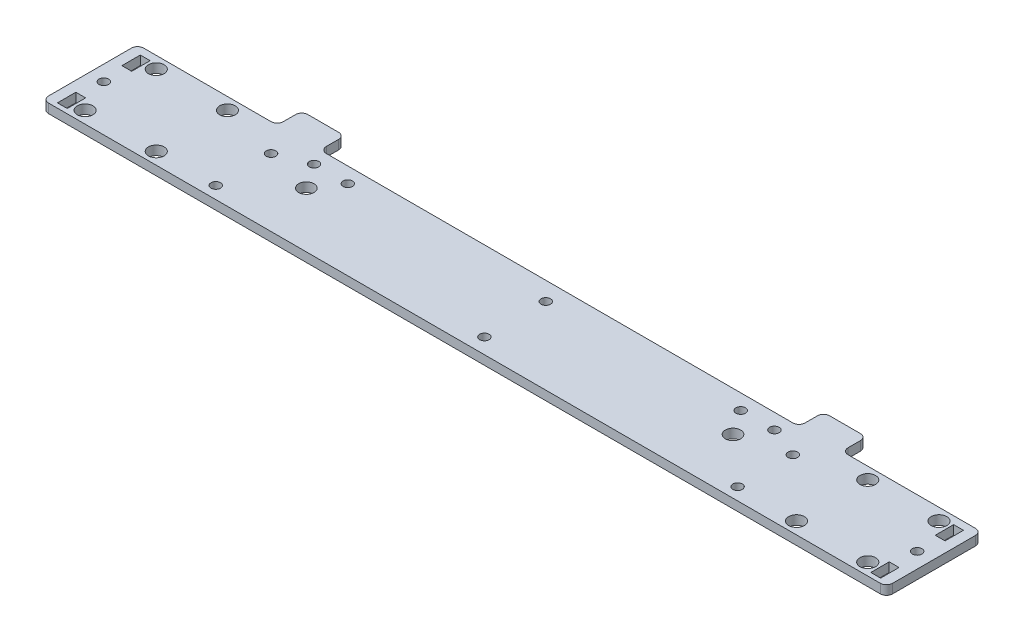
from build123d import *

# Parameters (mm, degrees)
CROQUIS1_R              = 1.55
CROQUIS1_R_2            = 2.55
CROQUIS1_R_3            = 2.5
CROQUIS1_W              = 3.2
CROQUIS1_H              = 6
SALIENTE_EXTRUIR1_DEPTH = 3
REDONDEO2_R             = 2


with BuildPart() as part:
    # Croquis1 → Saliente-Extruir1 (new body)
    with BuildSketch(Plane(origin=(0, 0, 0), x_dir=(1, 0, 0), z_dir=(0, 1, 0))):
        Polygon((0, 0), (275, 0), (275, 31), (229.5, 31), (229.5, 39), (215.5, 39), (215.5, 31), (59.5, 31), (59.5, 39), (45.5, 39), (45.5, 31), (0, 31), align=None)
        with Locations((5, 15)):
            Circle(CROQUIS1_R, mode=Mode.SUBTRACT)
        with Locations((270, 15)):
            Circle(CROQUIS1_R, mode=Mode.SUBTRACT)
        with Locations((10, 27.1)):
            Circle(CROQUIS1_R_2, mode=Mode.SUBTRACT)
        with Locations((33.2, 27.1)):
            Circle(CROQUIS1_R_2, mode=Mode.SUBTRACT)
        with Locations((33.2, 3.9)):
            Circle(CROQUIS1_R_2, mode=Mode.SUBTRACT)
        with Locations((10, 3.9)):
            Circle(CROQUIS1_R_2, mode=Mode.SUBTRACT)
        with Locations((265, 3.9)):
            Circle(CROQUIS1_R_2, mode=Mode.SUBTRACT)
        with Locations((241.8, 3.9)):
            Circle(CROQUIS1_R_2, mode=Mode.SUBTRACT)
        with Locations((265, 27.1)):
            Circle(CROQUIS1_R_2, mode=Mode.SUBTRACT)
        with Locations((241.8, 27.1)):
            Circle(CROQUIS1_R_2, mode=Mode.SUBTRACT)
        with Locations((139, 25)):
            Circle(CROQUIS1_R, mode=Mode.SUBTRACT)
        with Locations((139, 5)):
            Circle(CROQUIS1_R, mode=Mode.SUBTRACT)
        with Locations((52.5, 22)):
            Circle(CROQUIS1_R, mode=Mode.SUBTRACT)
        with Locations((52.5, 4)):
            Circle(CROQUIS1_R, mode=Mode.SUBTRACT)
        with Locations((222.5, 22)):
            Circle(CROQUIS1_R, mode=Mode.SUBTRACT)
        with Locations((222.5, 4)):
            Circle(CROQUIS1_R, mode=Mode.SUBTRACT)
        with Locations((212.5, 26)):
            Circle(CROQUIS1_R, mode=Mode.SUBTRACT)
        with Locations((62.5, 26)):
            Circle(CROQUIS1_R, mode=Mode.SUBTRACT)
        with Locations((201.5, 26)):
            Circle(CROQUIS1_R, mode=Mode.SUBTRACT)
        with Locations((73.5, 26)):
            Circle(CROQUIS1_R, mode=Mode.SUBTRACT)
        with Locations((207, 18)):
            Circle(CROQUIS1_R_3, mode=Mode.SUBTRACT)
        with Locations((68, 18)):
            Circle(CROQUIS1_R_3, mode=Mode.SUBTRACT)
        with Locations((270, 4.5)):
            Rectangle(CROQUIS1_W, CROQUIS1_H, mode=Mode.SUBTRACT)
        with Locations((5, 25.5)):
            Rectangle(CROQUIS1_W, CROQUIS1_H, mode=Mode.SUBTRACT)
        with Locations((5, 4.5)):
            Rectangle(CROQUIS1_W, CROQUIS1_H, mode=Mode.SUBTRACT)
        with Locations((270, 25.5)):
            Rectangle(CROQUIS1_W, CROQUIS1_H, mode=Mode.SUBTRACT)
    extrude(amount=SALIENTE_EXTRUIR1_DEPTH)

    # Redondeo2
    redondeo2_edges = [part.edges().sort_by_distance(p)[0] for p in [
        (0, 1.5, -31),
        (45.5, 1.5, -31),
        (45.5, 1.5, -39),
        (59.5, 1.5, -39),
        (59.5, 1.5, -31),
        (215.5, 1.5, -31),
        (215.5, 1.5, -39),
        (229.5, 1.5, -39),
        (229.5, 1.5, -31),
        (275, 1.5, -31),
        (275, 1.5, 0),
        (0, 1.5, 0),
    ]]
    fillet(redondeo2_edges, radius=REDONDEO2_R)


solid = part.part
